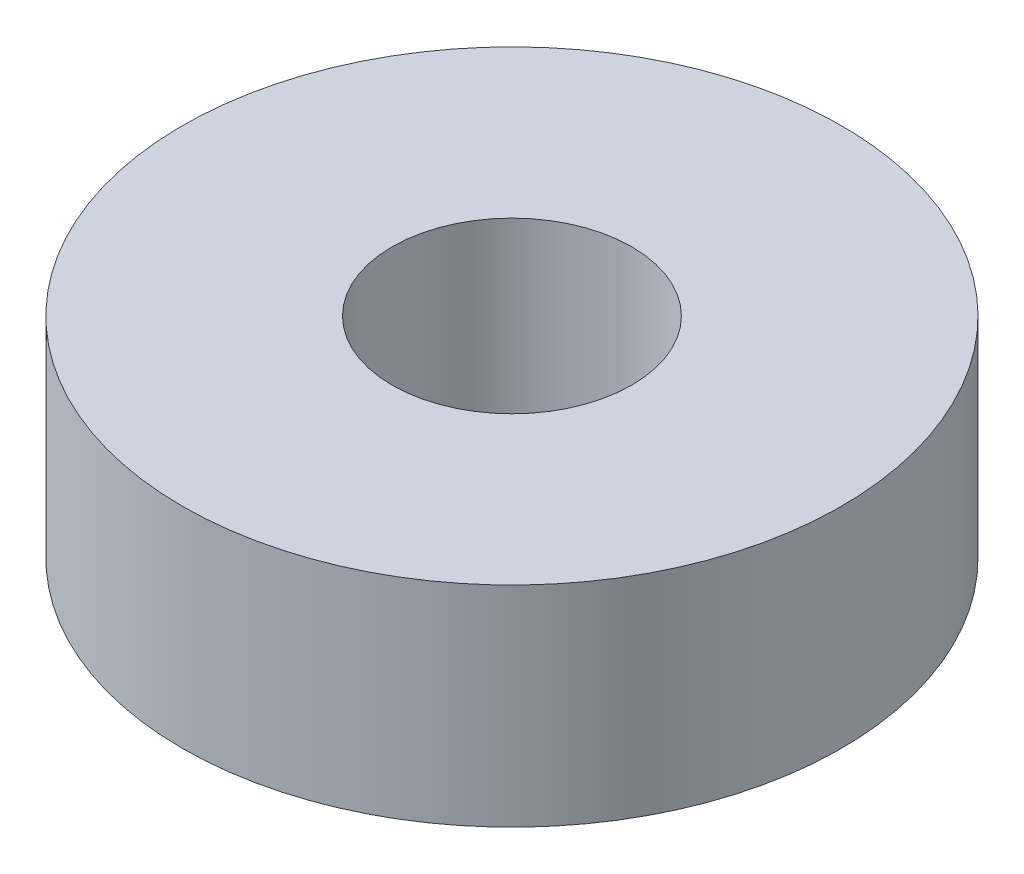
from build123d import *

# Parameters (mm, degrees)
CROQUIS1_R              = 11
CROQUIS1_R_2            = 4
SALIENTE_EXTRUIR1_DEPTH = 7


with BuildPart() as part:
    # Croquis1 → Saliente-Extruir1 (new body)
    with BuildSketch(Plane(origin=(0, 0, 0), x_dir=(1, 0, 0), z_dir=(0, 1, 0))):
        Circle(CROQUIS1_R)
        Circle(CROQUIS1_R_2, mode=Mode.SUBTRACT)
    extrude(amount=SALIENTE_EXTRUIR1_DEPTH)


solid = part.part
